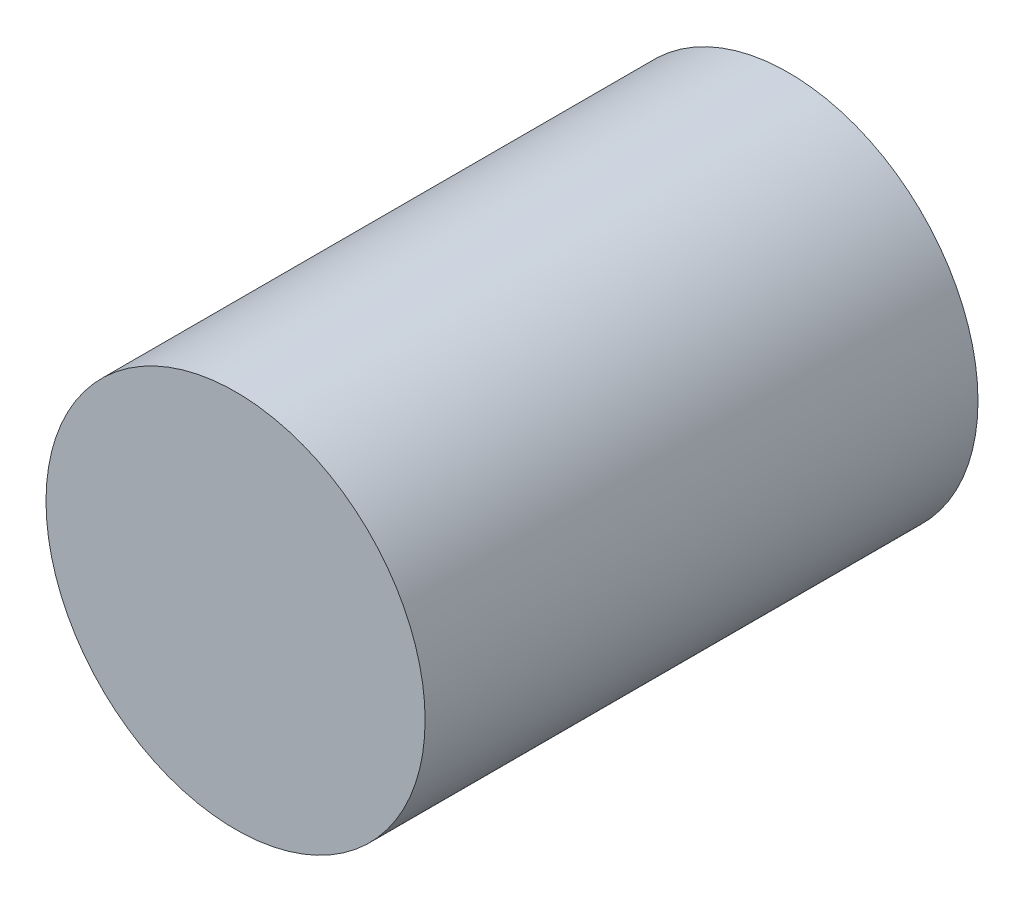
from build123d import *

# Parameters (mm, degrees)
SKETCH1_R      = 17.399
EXTRUDE1_DEPTH = 50.7492


with BuildPart() as part:
    # Sketch1 → Extrude1 (new body)
    with BuildSketch(Plane.XY):
        Circle(SKETCH1_R)
    extrude(amount=EXTRUDE1_DEPTH)


solid = part.part
